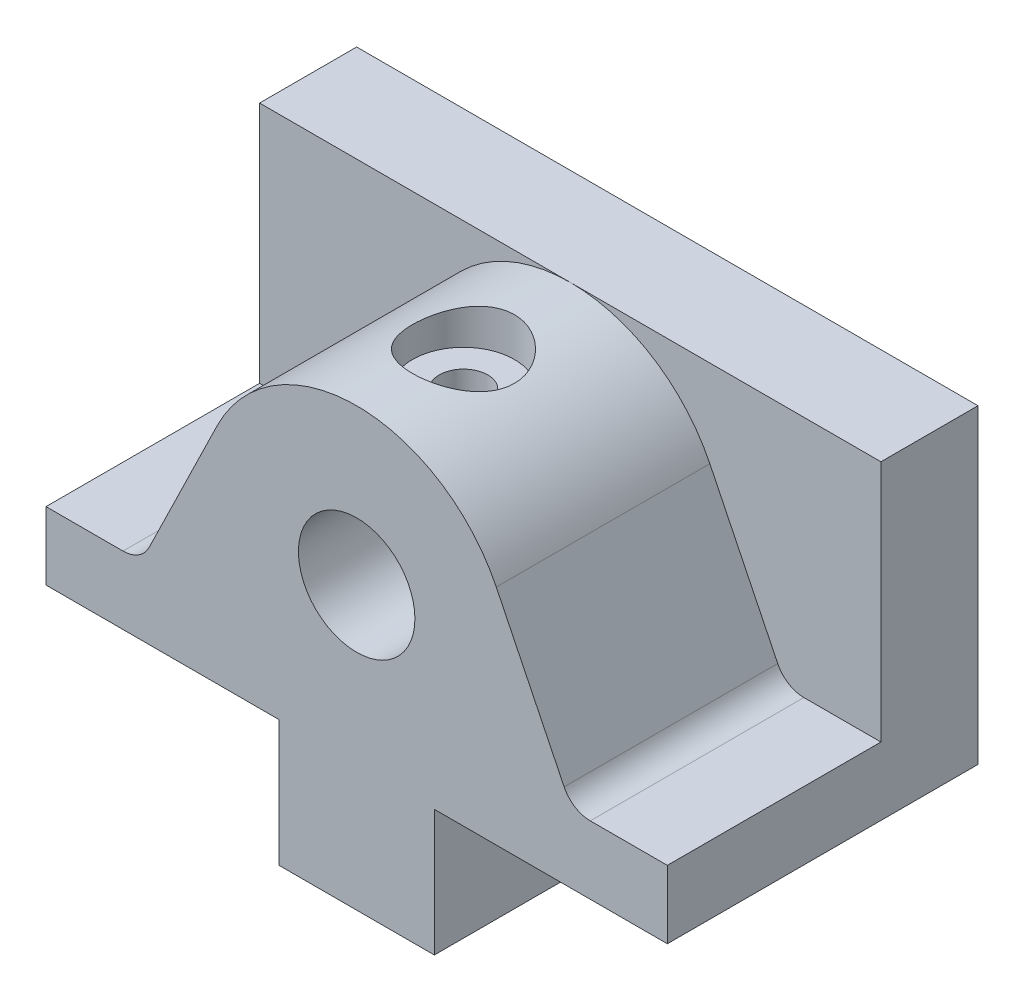
from build123d import *

# Parameters (mm, degrees)
IZIM1_W                     = 64
IZIM1_H                     = 32
Y_KSEKLIK_EKSTR_ZYON1_DEPTH = 32
Y_KSEKLIK_EKSTR_ZYON3_DEPTH = 32
IZIM3_R                     = 6
KES_EKSTR_ZYON3_DEPTH       = 22
KES_EKSTR_ZYON4_DEPTH       = 22
RADYUS1_R                   = 3
IZIM6_R                     = 5.25
KES_EKSTR_ZYON5_DEPTH       = 4
M6X1_0_DI_LI_DELIK1_REACH   = 58.089
M6X1_0_DI_LI_DELIK1_BORE_R  = 2.5
M6X1_0_DI_LI_DELIK2_D       = 5
M6X1_0_DI_LI_DELIK2_DEPTH   = 12
M6X1_0_DI_LI_DELIK2_TIP     = 1.502151548


with BuildPart() as part:
    # Çizim1 → Yükseklik-Ekstrüzyon1 (new body)
    with BuildSketch(Plane.XY):
        with Locations((-5.139018929, 9.134948097)):
            Rectangle(IZIM1_W, IZIM1_H)
    extrude(amount=Y_KSEKLIK_EKSTR_ZYON1_DEPTH)

    # Çizim2 → Yükseklik-Ekstrüzyon3 (add)
    with BuildSketch(Plane.XY.offset(32)):
        Polygon((-5.139018929, -19.865051903), (2.860981071, -19.865051903), (2.860981071, -6.865051903), (-5.139018929, -6.865051903), (-13.139018929, -6.865051903), (-13.139018929, -19.865051903), align=None)
    extrude(amount=-Y_KSEKLIK_EKSTR_ZYON3_DEPTH)

    # Çizim3 → Kes-Ekstrüzyon3 (cut)
    with BuildSketch(Plane.XY.offset(32)):
        with Locations((-5.139018929, 9.134948097)):
            Circle(IZIM3_R)
    extrude(amount=-KES_EKSTR_ZYON3_DEPTH, mode=Mode.SUBTRACT)

    # Çizim5 → Kes-Ekstrüzyon4 (cut)
    with BuildSketch(Plane.XY.offset(32)):
        with BuildLine():
            ThreePointArc((-19.51972367, 16.148886446), (-13.617727108, 22.703717666), (-5.139018815, 25.134948097))
            Line((-5.139018815, 25.134948097), (-37.139018929, 25.134948097))
            Line((-37.139018929, 25.134948097), (-37.139018929, 0.134948097))
            Line((-37.139018929, 0.134948097), (-27.330243274, 0.134948097))
            Line((-27.330243274, 0.134948097), (-19.51972367, 16.148886446))
        make_face()
        with BuildLine():
            ThreePointArc((-5.139018815, 25.134948097), (3.339689347, 22.703717605), (9.241685811, 16.148886446))
            Line((9.241685811, 16.148886446), (17.052205415, 0.134948097))
            Line((17.052205415, 0.134948097), (26.860981071, 0.134948097))
            Line((26.860981071, 0.134948097), (26.860981071, 25.134948097))
            Line((26.860981071, 25.134948097), (-5.139018815, 25.134948097))
        make_face()
    extrude(amount=-KES_EKSTR_ZYON4_DEPTH, mode=Mode.SUBTRACT)

    # Radyus1
    radyus1_edges = [part.edges().sort_by_distance(p)[0] for p in [
        (-27.330243274, 0.134948097, 21),
        (17.052205415, 0.134948097, 21),
    ]]
    fillet(radyus1_edges, radius=RADYUS1_R)

    # Çizim6 → Kes-Ekstrüzyon5 (cut)
    with BuildSketch(Plane(origin=(0, 25.134948097, 0), x_dir=(1, 0, 0), z_dir=(0, 1, 0))):
        with Locations(Location((-5.139018929, -21, 0), (0, 0, 270))):
            Circle(IZIM6_R)
    extrude(amount=-KES_EKSTR_ZYON5_DEPTH, mode=Mode.SUBTRACT)

    # M6x1.0 Dişli Delik1 bore (on position points) → M6x1.0 Dişli Delik1 (cut, up to next)
    with BuildSketch(Plane(origin=(-5.139018929, 21.134948097, 21), x_dir=(0, 0, 1), z_dir=(0, 1, 0)), mode=Mode.PRIVATE) as m6x1_0_di_li_delik1_sk1:
        Circle(M6X1_0_DI_LI_DELIK1_BORE_R)
    m6x1_0_di_li_delik1_tool1 = extrude(m6x1_0_di_li_delik1_sk1.sketch, amount=-M6X1_0_DI_LI_DELIK1_REACH, mode=Mode.PRIVATE) & part.part
    add(m6x1_0_di_li_delik1_tool1.solids().sort_by_distance((-5.139019, 21.134948, 21))[0], mode=Mode.SUBTRACT)

    # M6x1.0 Dişli Delik2
    with Locations(Plane(origin=(-5.139018929, -19.865051903, 24), x_dir=(0, 0, -1), z_dir=(0, -1, 0))):
        with Locations((0, 0), (16, 0)):
            Hole(M6X1_0_DI_LI_DELIK2_D / 2, depth=M6X1_0_DI_LI_DELIK2_DEPTH)
            with Locations((0, 0, -(M6X1_0_DI_LI_DELIK2_DEPTH + M6X1_0_DI_LI_DELIK2_TIP / 2))):  # 118° drill point
                Cone(0, M6X1_0_DI_LI_DELIK2_D / 2, M6X1_0_DI_LI_DELIK2_TIP, mode=Mode.SUBTRACT)


solid = part.part
